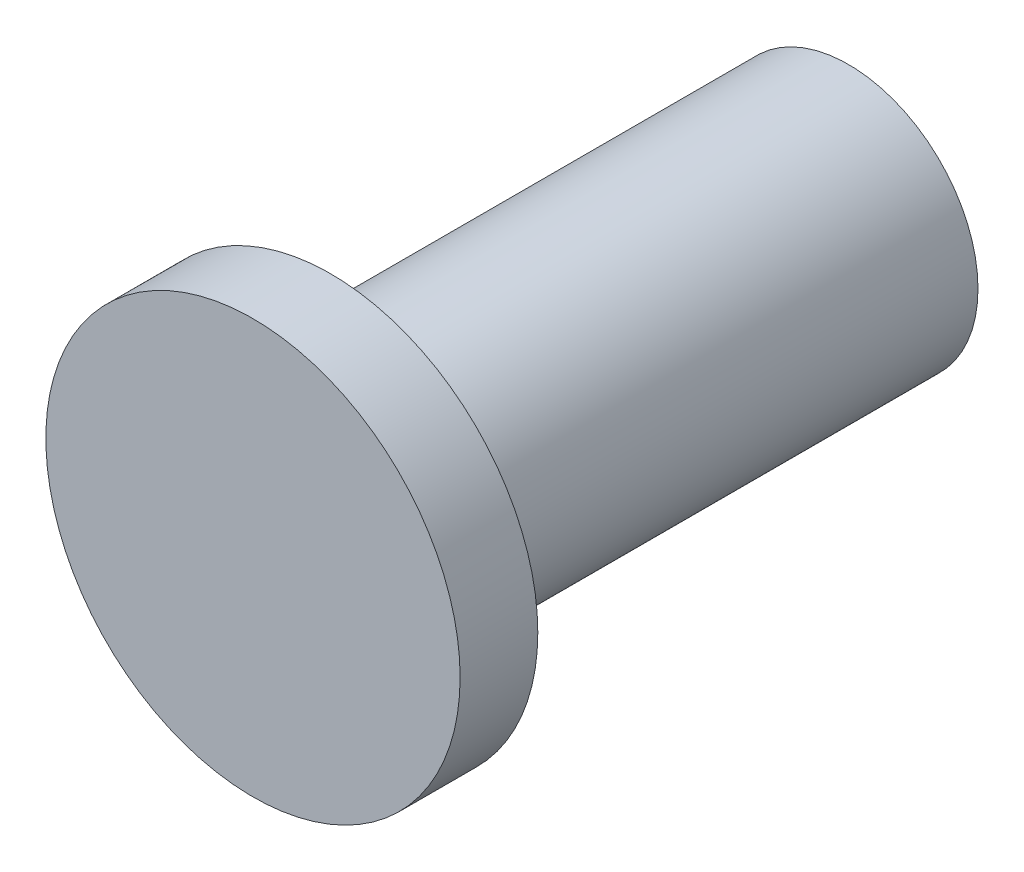
from build123d import *

# Parameters (mm, degrees)
SKETCH1_R           = 8
BOSS_EXTRUDE1_DEPTH = 3
SKETCH2_R           = 5
BOSS_EXTRUDE2_DEPTH = 10
SKETCH3_R           = 5
BOSS_EXTRUDE3_DEPTH = 10


with BuildPart() as part:
    # Sketch1 → Boss-Extrude1 (new body)
    with BuildSketch(Plane.XY):
        Circle(SKETCH1_R)
    extrude(amount=BOSS_EXTRUDE1_DEPTH)

    # Sketch2 → Boss-Extrude2 (add)
    with BuildSketch(Plane(origin=(0, 0, 0), x_dir=(-1, 0, 0), z_dir=(0, 0, -1))):
        Circle(SKETCH2_R)
    extrude(amount=BOSS_EXTRUDE2_DEPTH)

    # Sketch3 → Boss-Extrude3 (add)
    with BuildSketch(Plane(origin=(0, 0, -10), x_dir=(-1, 0, 0), z_dir=(0, 0, -1))):
        Circle(SKETCH3_R)
    extrude(amount=BOSS_EXTRUDE3_DEPTH)


solid = part.part
